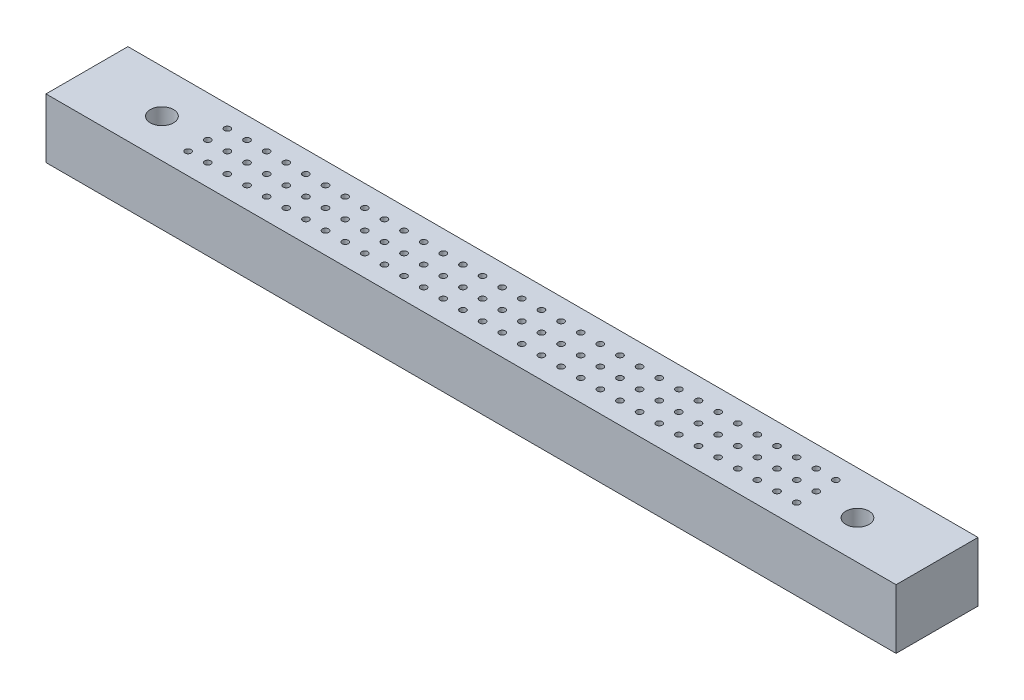
from build123d import *

# Parameters (mm, degrees)
SKETCH1_W                  = 110
SKETCH1_H                  = 10
SKETCH1_R                  = 1.5
BOSS_EXTRUDE1_DEPTH        = 7.7
F_0_8_0_8_DIAMETER_HOLE1_D = 0.8
LPATTERN1_COUNT            = 32
LPATTERN1_PITCH            = 2.54
SKETCH6_W                  = 110
SKETCH6_H                  = 7.7
BOSS_EXTRUDE4_DEPTH        = 0.6
F_1_0MM_DOWEL_HOLE2_D      = 1
F_1_0MM_DOWEL_HOLE2_DEPTH  = 4
F_1_0MM_DOWEL_HOLE2_TIP    = 0.30043031


with BuildPart() as part:
    # Sketch1 → Boss-Extrude1 (new body)
    with BuildSketch(Plane(origin=(0, 0, 0), x_dir=(1, 0, 0), z_dir=(0, 1, 0))):
        Rectangle(SKETCH1_W, SKETCH1_H)
        with Locations((45, 0)):
            Circle(SKETCH1_R, mode=Mode.SUBTRACT)
        with Locations((-45, 0)):
            Circle(SKETCH1_R, mode=Mode.SUBTRACT)
    extrude(amount=BOSS_EXTRUDE1_DEPTH)

    # Ø0.8 (0.8) Diameter Hole1 (through all)
    with Locations(Plane(origin=(-39.37, 7.7, -2.84), x_dir=(0, 0, 1), z_dir=(0, 1, 0))):
        with Locations((0, 0), (2.54, 0), (5.08, 0)):
            f_0_8_0_8_diameter_hole1 = Hole(F_0_8_0_8_DIAMETER_HOLE1_D / 2)

    # LPattern1: Ø0.8 (0.8) Diameter Hole1 ×32
    with Locations(*[(i * LPATTERN1_PITCH, 0, 0) for i in range(1, LPATTERN1_COUNT)]):
        add(f_0_8_0_8_diameter_hole1, mode=Mode.SUBTRACT)

    # Sketch6 → Boss-Extrude4 (add)
    with BuildSketch(Plane(origin=(0, 0, -5), x_dir=(-1, 0, 0), z_dir=(0, 0, -1))):
        with Locations((0, 3.85)):
            Rectangle(SKETCH6_W, SKETCH6_H)
    extrude(amount=BOSS_EXTRUDE4_DEPTH)

    # Ø1.0mm Dowel Hole2
    with Locations(Plane(origin=(-50, 0, -0.3), x_dir=(0, 0, -1), z_dir=(0, -1, 0))):
        with Locations((0, 0), (0, 100)):
            Hole(F_1_0MM_DOWEL_HOLE2_D / 2, depth=F_1_0MM_DOWEL_HOLE2_DEPTH)
            with Locations((0, 0, -(F_1_0MM_DOWEL_HOLE2_DEPTH + F_1_0MM_DOWEL_HOLE2_TIP / 2))):  # 118° drill point
                Cone(0, F_1_0MM_DOWEL_HOLE2_D / 2, F_1_0MM_DOWEL_HOLE2_TIP, mode=Mode.SUBTRACT)


solid = part.part
